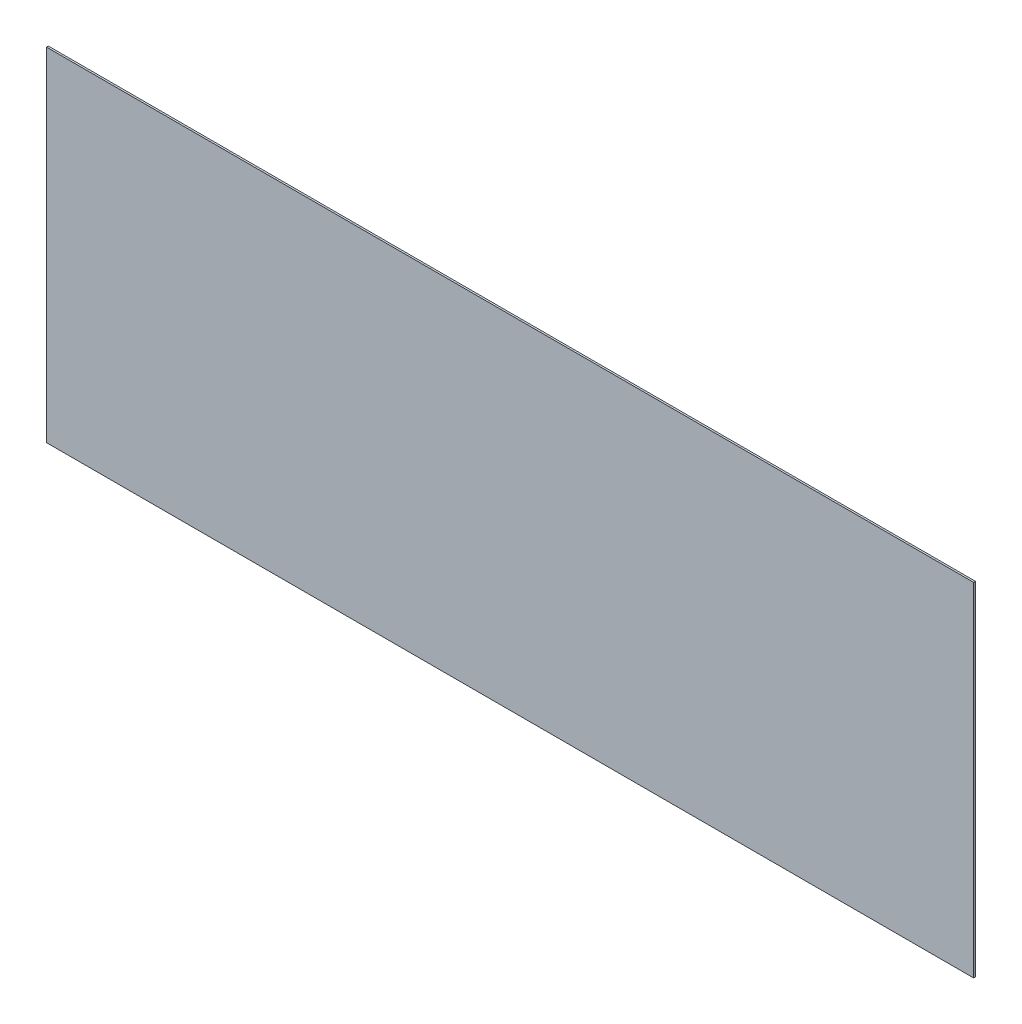
from build123d import *

# Parameters (mm, degrees)
SKETCH1_W           = 1581.15
SKETCH1_H           = 584.2
BOSS_EXTRUDE1_DEPTH = 3.175


with BuildPart() as part:
    # Sketch1 → Boss-Extrude1 (new body)
    with BuildSketch(Plane.XY):
        Rectangle(SKETCH1_W, SKETCH1_H)
    extrude(amount=BOSS_EXTRUDE1_DEPTH)


solid = part.part
